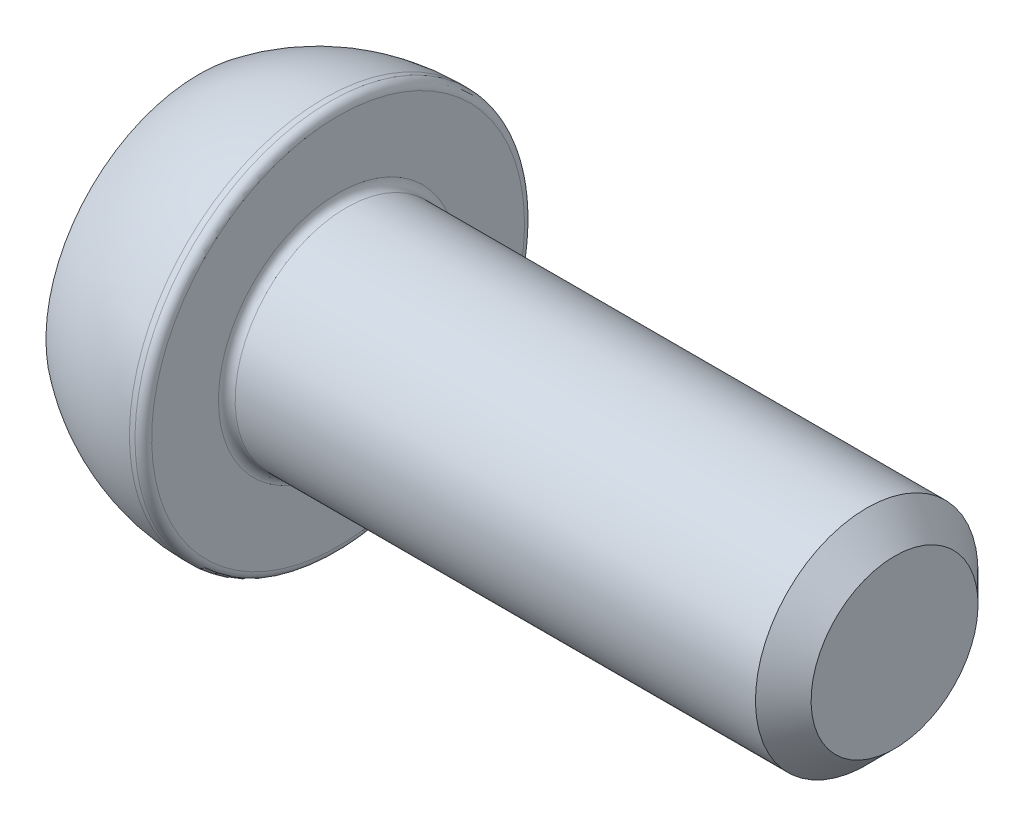
from build123d import *

# Parameters (mm, degrees)
CUT_EXTRUDE_1_DEPTH = 3
FILLET_1_R          = 0.3
CHAMFER_1_SIZE      = 1


with BuildPart() as part:
    # Эскиз1 → Повернуть1 (revolve)
    with BuildSketch(Plane.XY):
        with BuildLine():
            Line((0, 0), (0, 5.5))
            ThreePointArc((0, 5.5), (2.128291755, 6.615124735), (4.5, 7))
            Line((4.5, 7), (5, 7))
            Line((5, 7), (5, 4))
            Line((5, 4), (25, 4))
            Line((25, 4), (25, 0))
            Line((25, 0), (0, 0))
        make_face()
    revolve(axis=Axis((25, 0, 0), (-1, 0, 0)))

    # Эскиз2 → Вырез-Вытянуть1 (cut)
    with BuildSketch(Plane.ZY):
        Polygon((1.732050808, 3), (-1.732050808, 3), (-3.464101615, 0), (-1.732050808, -3), (1.732050808, -3), (3.464101615, 0), align=None)
    extrude(amount=-CUT_EXTRUDE_1_DEPTH, mode=Mode.SUBTRACT)

    # Скругление1
    fillet_1_edges = [part.edges().sort_by_distance(p)[0] for p in [
        (5, -4, 0),
        (5, -7, 0),
    ]]
    fillet(fillet_1_edges, radius=FILLET_1_R)

    # Фаска1
    chamfer_1_edges = [part.edges().sort_by_distance(p)[0] for p in [
        (25, -4, 0),
    ]]
    chamfer(chamfer_1_edges, length=CHAMFER_1_SIZE)


solid = part.part
